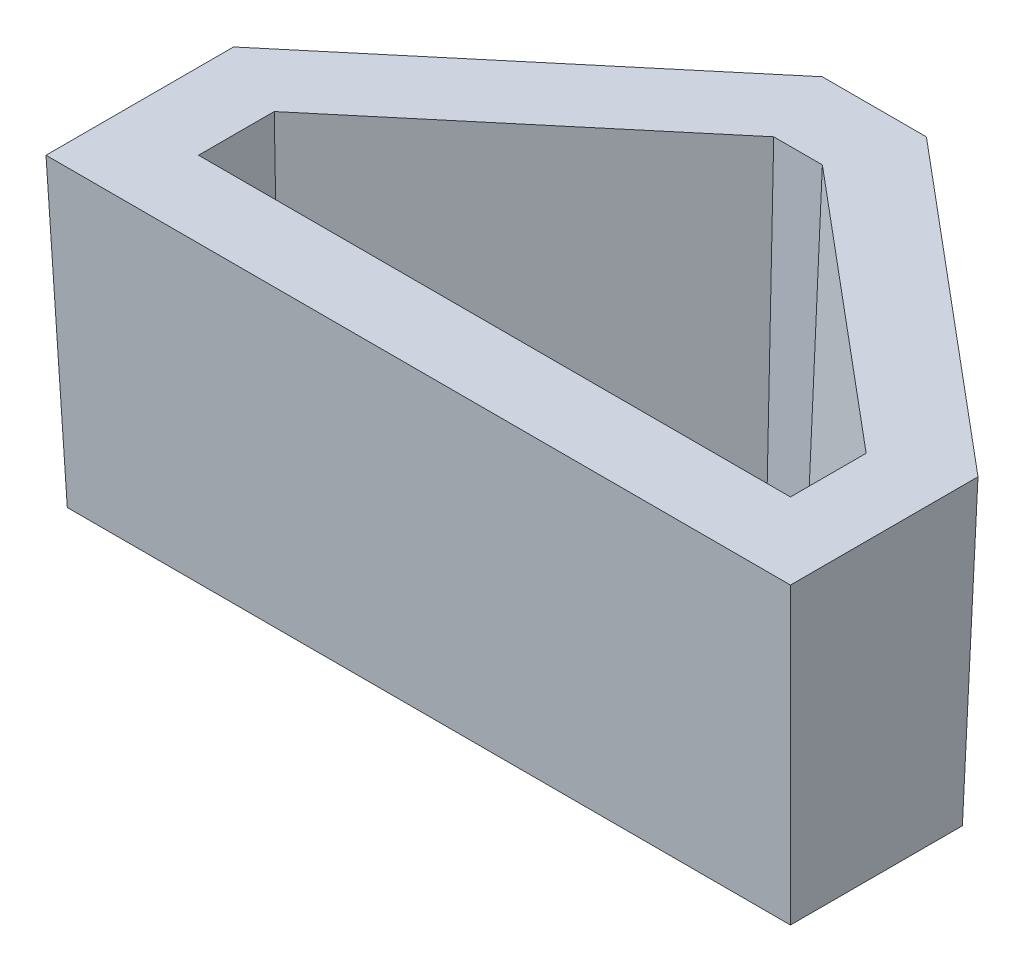
from build123d import *

# Parameters (mm, degrees)
SALIENTE_EXTRUIR1_DEPTH = 2.54
SALIENTE_EXTRUIR2_DEPTH = 50.8
SALIENTE_EXTRUIR2_TAPER = 2
CORTAR_EXTRUIR1_DEPTH   = 50.8
CORTAR_EXTRUIR1_TAPER   = 2


with BuildPart() as part:
    # Croquis1 → Saliente-Extruir1 (new body)
    with BuildSketch(Plane(origin=(0, 0, 0), x_dir=(1, 0, 0), z_dir=(0, 1, 0))):
        Polygon((0, 0), (98.55, 0), (98.55, 12.6), (53.325, 50.537320346), (45.225, 50.537320346), (0, 12.6), align=None)
    extrude(amount=-SALIENTE_EXTRUIR1_DEPTH)

    # Croquis2 → Saliente-Extruir2 (add)
    with BuildSketch(Plane(origin=(0, 0, 0), x_dir=(1, 0, 0), z_dir=(0, 1, 0))):
        Polygon((-12.7, 18.52320689), (-12.7, -12.7), (111.25, -12.7), (111.25, 18.52320689), (57.94639915, 63.237320346), (40.60360085, 63.237320346), align=None)
    extrude(amount=-SALIENTE_EXTRUIR2_DEPTH, taper=SALIENTE_EXTRUIR2_TAPER)

    # Croquis3 → Cortar-Extruir1 (cut)
    with BuildSketch(Plane(origin=(0, 0, 0), x_dir=(1, 0, 0), z_dir=(0, 1, 0))):
        Polygon((0, 0), (98.55, 0), (98.55, 12.6), (53.325, 50.537320346), (45.225, 50.537320346), (0, 12.6), align=None)
    extrude(amount=-CORTAR_EXTRUIR1_DEPTH, taper=CORTAR_EXTRUIR1_TAPER, mode=Mode.SUBTRACT)


solid = part.part
